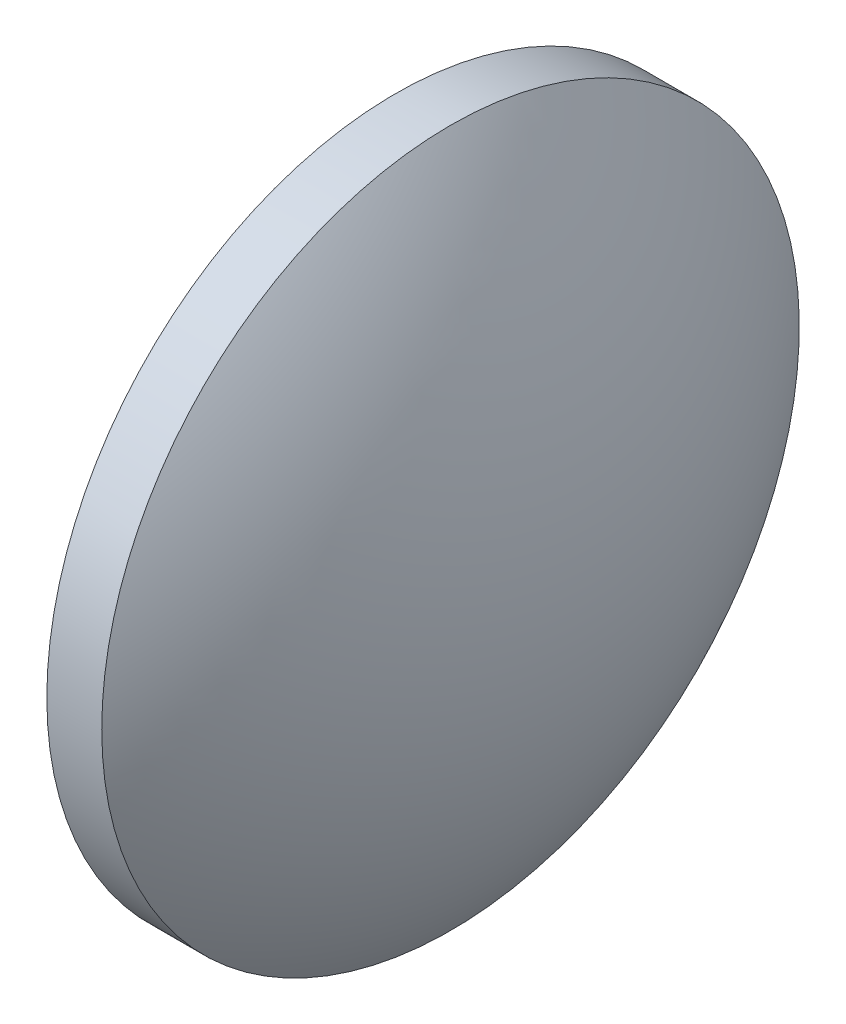
from build123d import *


with BuildPart() as part:
    # 草图1 → 旋转1 (revolve)
    with BuildSketch(Plane.XY):
        with BuildLine():
            Line((679.410345435, 68.036164603), (679.410345435, 80.736164603))
            Line((679.410345435, 80.736164603), (681.410345435, 80.736164603))
            ThreePointArc((681.410345435, 80.736164603), (684.459945703, 74.708870201), (685.510345435, 68.036164603))
            Line((685.510345435, 68.036164603), (679.410345435, 68.036164603))
        make_face()
    revolve(axis=Axis((673.6721274, 68.036164603, 0), (1, 0, 0)))


solid = part.part
